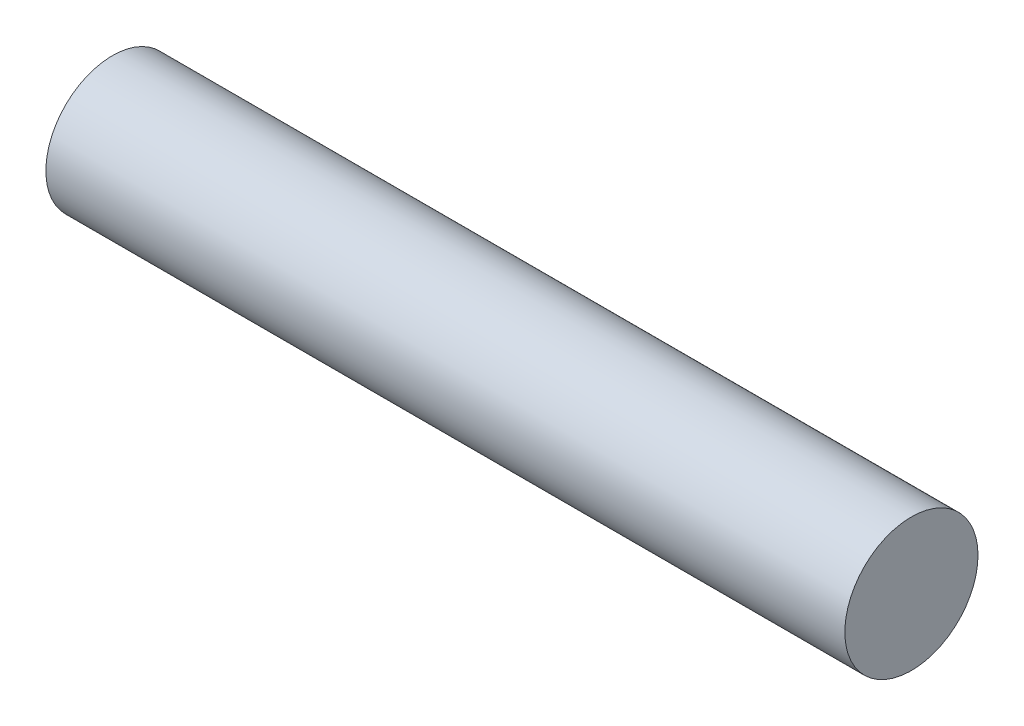
from build123d import *

# Parameters (mm, degrees)
CROQUIS1_R              = 3.175
SALIENTE_EXTRUIR1_DEPTH = 38.1


with BuildPart() as part:
    # Croquis1 → Saliente-Extruir1 (new body)
    with BuildSketch(Plane(origin=(0, 0, 0), x_dir=(0, 0, -1), z_dir=(1, 0, 0))):
        Circle(CROQUIS1_R)
    extrude(amount=SALIENTE_EXTRUIR1_DEPTH)


solid = part.part
